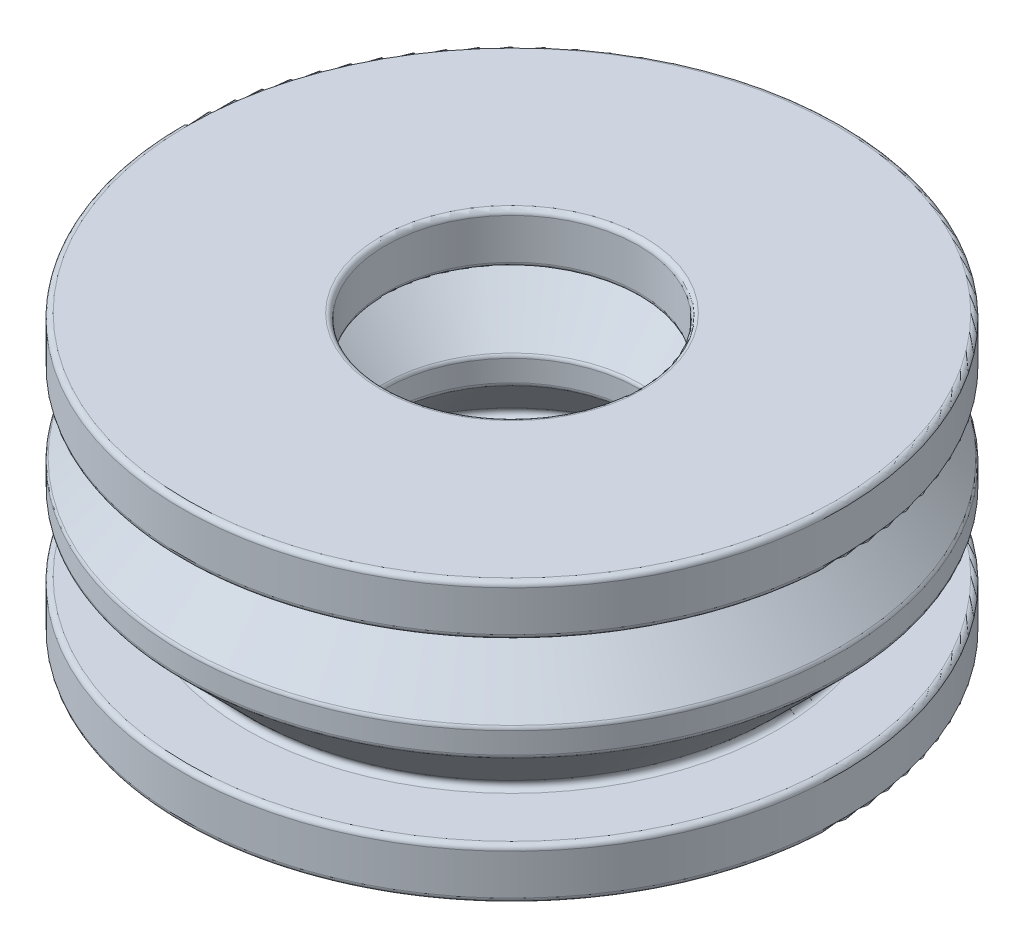
from build123d import *


with BuildPart() as part:
    # 草图1 → 旋转1 (revolve)
    with BuildSketch(Plane.XY):
        with BuildLine():
            Line((-5, 0.2), (-5, 1.8))
            ThreePointArc((-5, 1.8), (-5.058578644, 1.941421356), (-5.2, 2))
            Line((-5.2, 2), (-7.517157288, 2))
            ThreePointArc((-7.517157288, 2), (-7.701933194, 2.123463314), (-7.658578644, 2.341421356))
            Line((-7.658578644, 2.341421356), (-5.058578644, 4.941421356))
            ThreePointArc((-5.058578644, 4.941421356), (-5.015224093, 5.006306026), (-5, 5.082842712))
            Line((-5, 5.082842712), (-5, 5.917157288))
            ThreePointArc((-5, 5.917157288), (-5.015224093, 5.993693974), (-5.058578644, 6.058578644))
            Line((-5.058578644, 6.058578644), (-7.658578644, 8.658578644))
            ThreePointArc((-7.658578644, 8.658578644), (-7.701933194, 8.876536686), (-7.517157288, 9))
            Line((-7.517157288, 9), (-5.2, 9))
            ThreePointArc((-5.2, 9), (-5.058578644, 9.058578644), (-5, 9.2))
            Line((-5, 9.2), (-5, 10.8))
            ThreePointArc((-5, 10.8), (-5.058578644, 10.941421356), (-5.2, 11))
            Line((-5.2, 11), (-12.8, 11))
            ThreePointArc((-12.8, 11), (-12.941421356, 10.941421356), (-13, 10.8))
            Line((-13, 10.8), (-13, 9.2))
            ThreePointArc((-13, 9.2), (-12.941421356, 9.058578644), (-12.8, 9))
            Line((-12.8, 9), (-10.482842712, 9))
            ThreePointArc((-10.482842712, 9), (-10.298066806, 8.876536686), (-10.341421356, 8.658578644))
            Line((-10.341421356, 8.658578644), (-12.941421356, 6.058578644))
            ThreePointArc((-12.941421356, 6.058578644), (-12.984775907, 5.993693974), (-13, 5.917157288))
            Line((-13, 5.917157288), (-13, 5.082842712))
            ThreePointArc((-13, 5.082842712), (-12.984775907, 5.006306026), (-12.941421356, 4.941421356))
            Line((-12.941421356, 4.941421356), (-10.341421356, 2.341421356))
            ThreePointArc((-10.341421356, 2.341421356), (-10.298066806, 2.123463314), (-10.482842712, 2))
            Line((-10.482842712, 2), (-12.8, 2))
            ThreePointArc((-12.8, 2), (-12.941421356, 1.941421356), (-13, 1.8))
            Line((-13, 1.8), (-13, 0.2))
            ThreePointArc((-13, 0.2), (-12.941421356, 0.058578644), (-12.8, 0))
            Line((-12.8, 0), (-5.2, 0))
            ThreePointArc((-5.2, 0), (-5.058578644, 0.058578644), (-5, 0.2))
        make_face()
    revolve(axis=Axis((0, 0, 0), (0, 1, 0)))


solid = part.part
